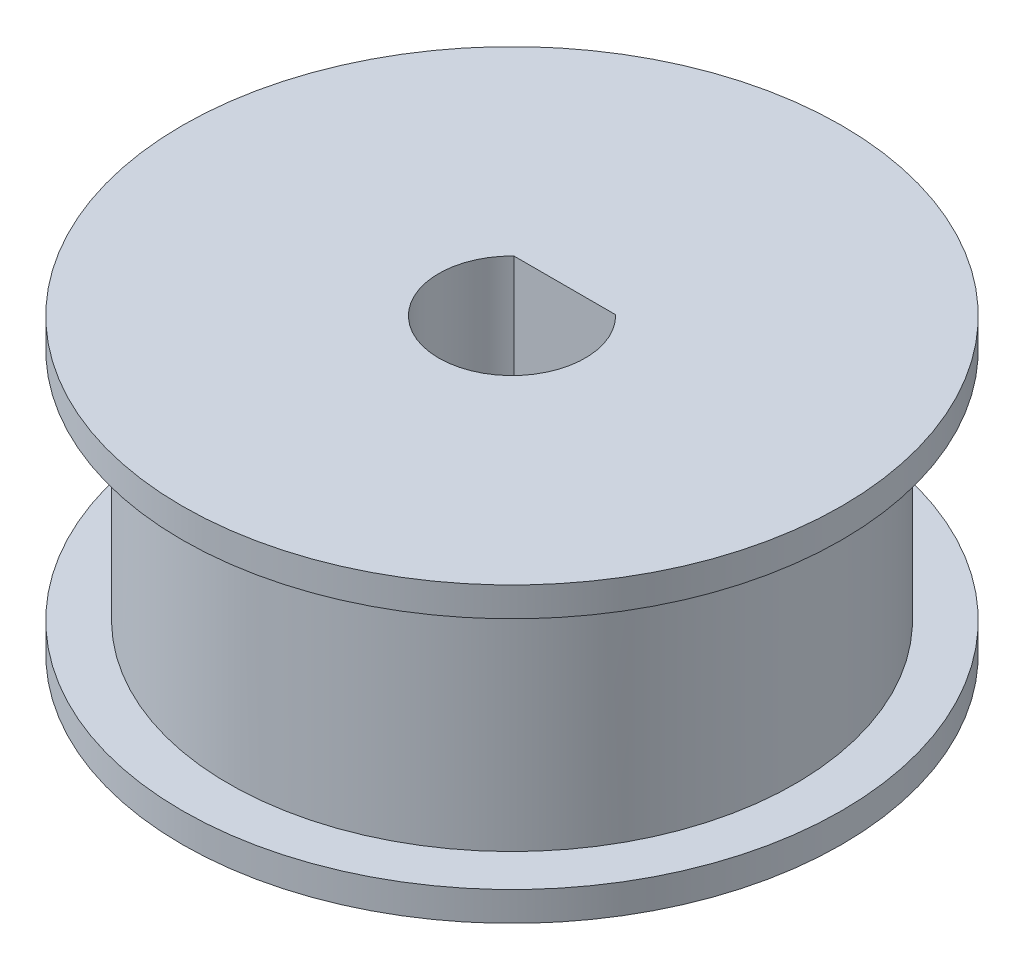
from build123d import *

# Parameters (mm, degrees)
SKETCH_1_R          = 19.325
SKETCH_1_R_2        = 2.5
EXTRUDE_1_DEPTH     = 16
SKETCH_2_R          = 22.5
SKETCH_2_R_2        = 2.5
EXTRUDE_2_DEPTH     = 2
SKETCH_3_R          = 22.5
SKETCH_3_R_2        = 2.5
EXTRUDE_3_DEPTH     = 2
CUT_EXTRUDE_1_REACH = 22


with BuildPart() as part:
    # 草图1 → 凸台-拉伸1 (new body)
    with BuildSketch(Plane(origin=(0, 0, 0), x_dir=(1, 0, 0), z_dir=(0, 1, 0))):
        Circle(SKETCH_1_R)
        Circle(SKETCH_1_R_2, mode=Mode.SUBTRACT)
    extrude(amount=EXTRUDE_1_DEPTH)

    # 草图2 → 凸台-拉伸2 (add)
    with BuildSketch(Plane(origin=(0, 16, 0), x_dir=(1, 0, 0), z_dir=(0, 1, 0))):
        Circle(SKETCH_2_R)
        Circle(SKETCH_2_R_2, mode=Mode.SUBTRACT)
    extrude(amount=EXTRUDE_2_DEPTH)

    # 草图3 → 凸台-拉伸3 (add)
    with BuildSketch(Plane.XZ):
        Circle(SKETCH_3_R)
        Circle(SKETCH_3_R_2, mode=Mode.SUBTRACT)
    extrude(amount=EXTRUDE_3_DEPTH)

    # 草图4 → 切除-拉伸1 (cut, up to next)
    with BuildSketch(Plane(origin=(0, 18, 0), x_dir=(1, 0, 0), z_dir=(0, 1, 0)), mode=Mode.PRIVATE) as cut_extrude_1_sk1:
        with BuildLine():
            Line((-3.469870315, 3.6), (3.469870315, 3.6))
            ThreePointArc((3.469870315, 3.6), (0, -5), (-3.469870315, 3.6))
        make_face()
    cut_extrude_1_tool1 = extrude(cut_extrude_1_sk1.sketch, amount=-CUT_EXTRUDE_1_REACH, mode=Mode.PRIVATE) & part.part
    add(cut_extrude_1_tool1.solids().sort_by_distance((0, 18, 0.387599))[0], mode=Mode.SUBTRACT)


solid = part.part
